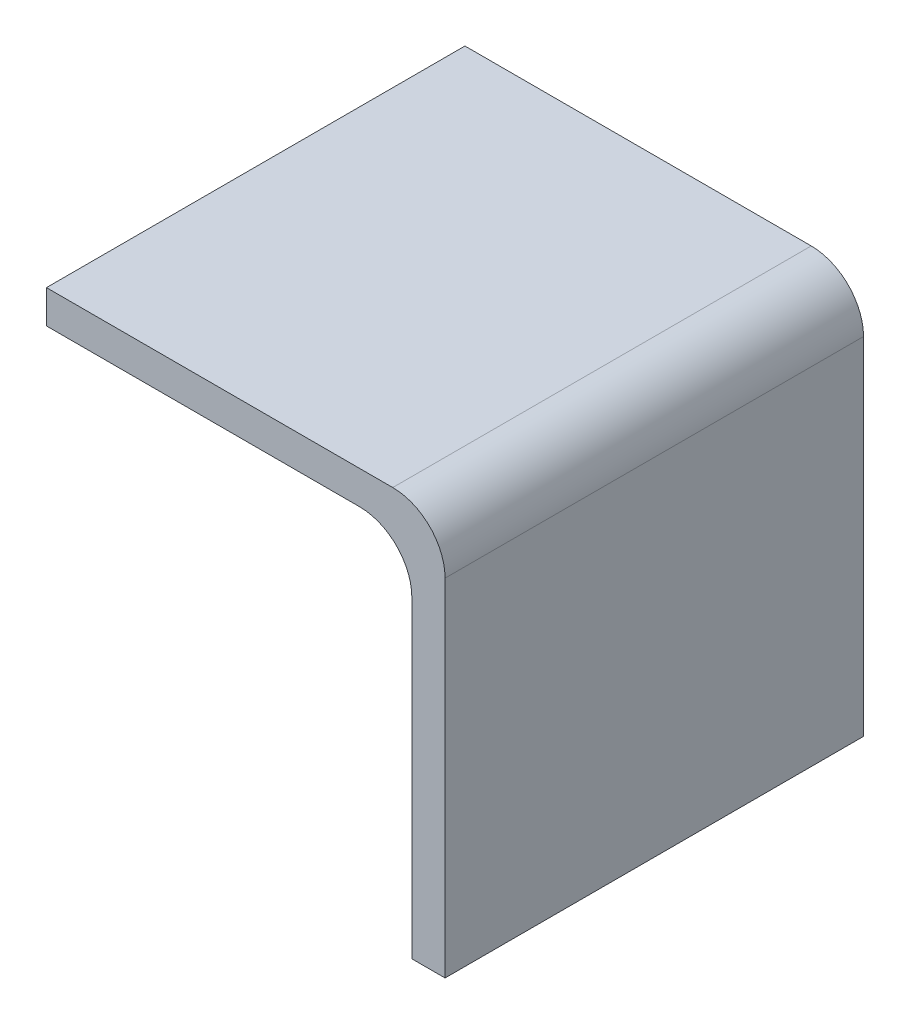
from build123d import *

# Parameters (mm, degrees)
BOSS_EXTRUDE1_DEPTH = 40
FILLET1_R           = 5
FILLET2_R           = 5


with BuildPart() as part:
    # Sketch1 → Boss-Extrude1 (new body)
    with BuildSketch(Plane.XY):
        Polygon((0, 0), (34.925, 0), (34.925, -34.925), (38.1, -34.925), (38.1, 0), (38.1, 3.175), (0, 3.175), align=None)
    extrude(amount=BOSS_EXTRUDE1_DEPTH)

    # Fillet1
    fillet1_edges = [part.edges().sort_by_distance(p)[0] for p in [
        (34.925, 0, 20),
    ]]
    fillet(fillet1_edges, radius=FILLET1_R)

    # Fillet2
    fillet2_edges = [part.edges().sort_by_distance(p)[0] for p in [
        (38.1, 3.175, 20),
    ]]
    fillet(fillet2_edges, radius=FILLET2_R)


solid = part.part
